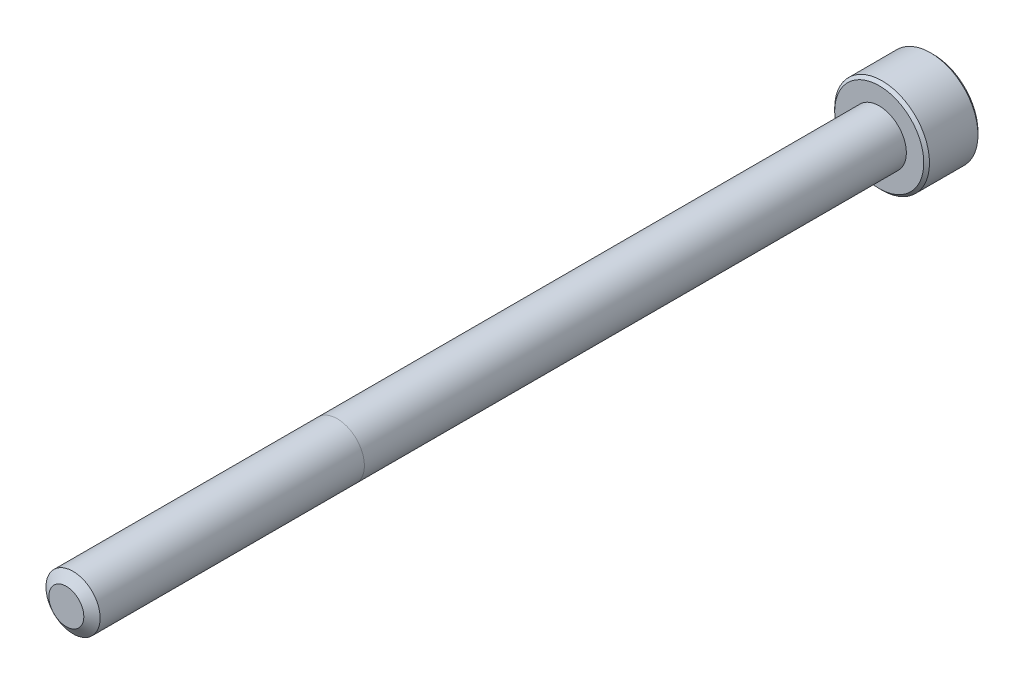
from build123d import *

# Parameters (mm, degrees)
SKETCH1_R          = 2
EXTRUDE1_DEPTH     = 60
SKETCH6_R          = 3.5
EXTRUDE2_DEPTH     = 4
CUT_EXTRUDE1_DEPTH = 2.25
CHAMFER1_SIZE      = 0.21


with BuildPart() as part:
    # Sketch1 → Extrude1 (new body)
    with BuildSketch(Plane.XY):
        Circle(SKETCH1_R)
    extrude(amount=-EXTRUDE1_DEPTH)

    # Sketch4 → Cut-Revolve1 (revolve, cut)
    with BuildSketch(Plane(origin=(0, 0, 0), x_dir=(0, 0, -1), z_dir=(1, 0, 0))):
        Polygon((0.496211411, 2), (0, 1.291336663), (0, 2), align=None)
    revolve(axis=Axis((0, 0, 0), (0, 0, -1)), mode=Mode.SUBTRACT)

    # Sketch6 → Extrude2 (add)
    with BuildSketch(Plane(origin=(0, 0, -60), x_dir=(-1, 0, 0), z_dir=(0, 0, -1))):
        Circle(SKETCH6_R)
    extrude(amount=EXTRUDE2_DEPTH)

    # Sketch7 → Cut-Extrude1 (cut)
    with BuildSketch(Plane(origin=(0, 0, -64), x_dir=(-1, 0, 0), z_dir=(0, 0, -1))):
        Polygon((0, 1.732050808), (-1.5, 0.866025404), (-1.5, -0.866025404), (0, -1.732050808), (1.5, -0.866025404), (1.5, 0.866025404), align=None)
    extrude(amount=-CUT_EXTRUDE1_DEPTH, mode=Mode.SUBTRACT)

    # Cut-Extrude2 cone 1 section (through the dimple's axis) → Cut-Extrude2 (revolve, cut)
    with BuildSketch(Plane(origin=(0, 0, -64), x_dir=(0, 1, 0), z_dir=(1, 0, 0))):
        Polygon((0, 0), (1.732050808, 0), (0, 1.732050808), align=None)
    revolve(axis=Axis((0, 0, -64), (0, 0, 1)), mode=Mode.SUBTRACT)

    # Chamfer1
    chamfer1_edges = [part.edges().sort_by_distance(p)[0] for p in [
        (3.5, 0, -64),
        (3.5, 0, -60),
    ]]
    chamfer(chamfer1_edges, length=CHAMFER1_SIZE)

    # Sketch10 → Revolve1 (revolve)
    with BuildSketch(Plane(origin=(0, 0, 0), x_dir=(0, 0, -1), z_dir=(1, 0, 0))):
        Polygon((60, 2), (60, 0), (58.996572875, 0), (59.825, 2), align=None)
    revolve(axis=Axis((0, 0, -60), (0, 0, 1)))


solid = part.part
